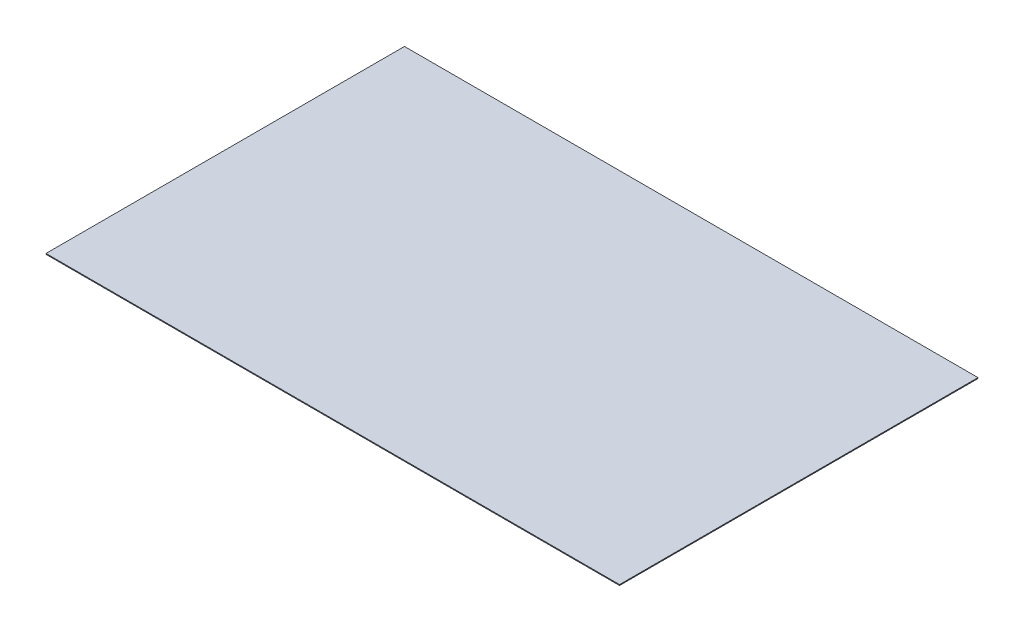
from build123d import *

# Parameters (mm, degrees)
SKETCH3_W           = 406.4
SKETCH3_H           = 0.6096
BOSS_EXTRUDE1_DEPTH = 127


with BuildPart() as part:
    # Sketch3 → Boss-Extrude1 (new body, symmetric)
    with BuildSketch(Plane.XY):
        Rectangle(SKETCH3_W, SKETCH3_H)
    extrude(amount=BOSS_EXTRUDE1_DEPTH, both=True)


solid = part.part
